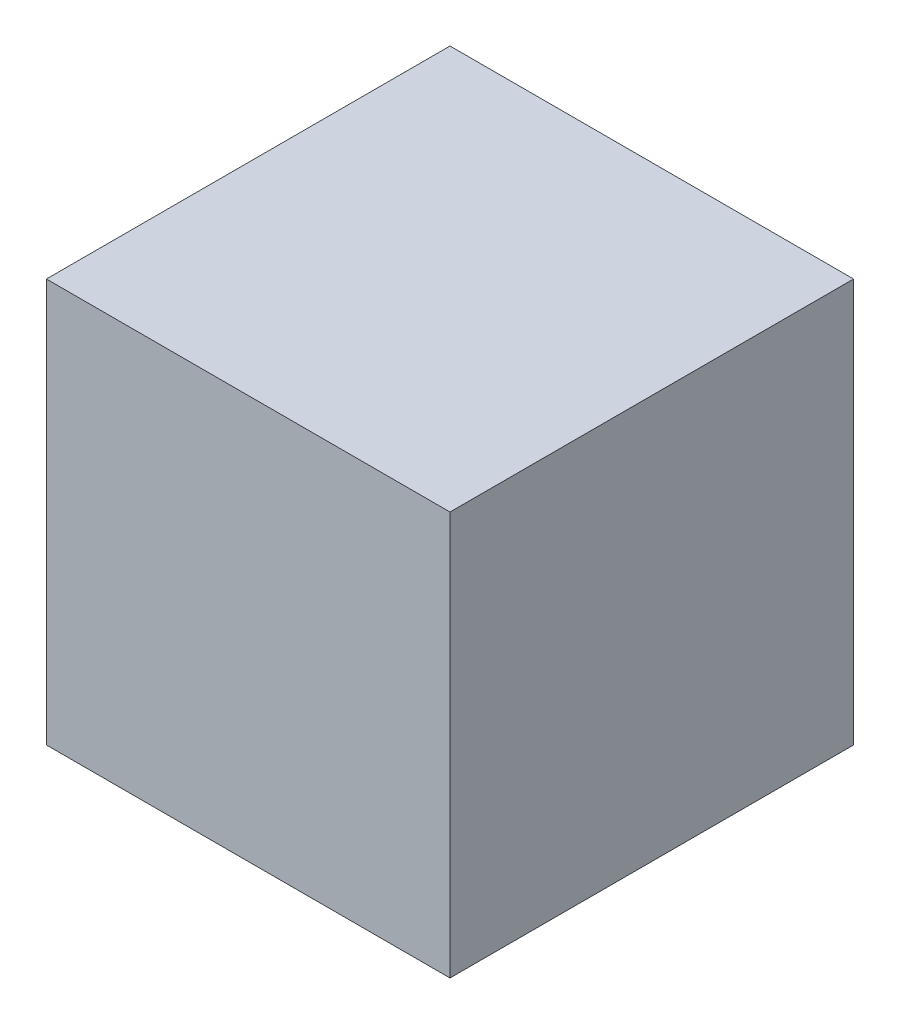
from build123d import *

# Parameters (mm, degrees)
SKETCH1_W           = 50
SKETCH1_H           = 50
BOSS_EXTRUDE1_DEPTH = 50


with BuildPart() as part:
    # Sketch1 → Boss-Extrude1 (new body)
    with BuildSketch(Plane(origin=(0, 0, 0), x_dir=(1, 0, 0), z_dir=(0, 1, 0))):
        Rectangle(SKETCH1_W, SKETCH1_H)
    extrude(amount=BOSS_EXTRUDE1_DEPTH)


solid = part.part
